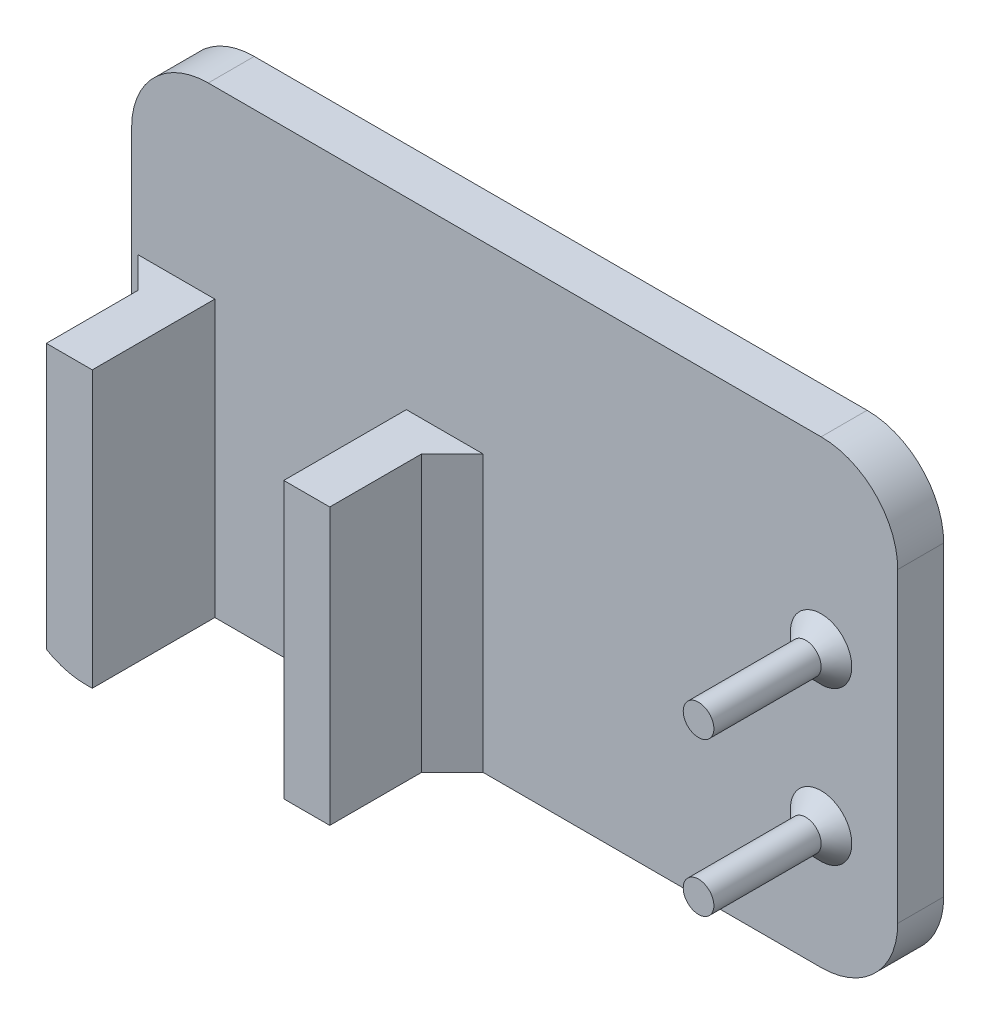
from build123d import *

# Parameters (mm, degrees)
SKETCH1_W           = 50
SKETCH1_H           = 30
BOSS_EXTRUDE1_DEPTH = 3
SKETCH2_W           = 3
SKETCH2_H           = 18
SKETCH2_R           = 1
BOSS_EXTRUDE2_DEPTH = 8
CHAMFER1_SIZE       = 2
FILLET1_R           = 5
CHAMFER3_SIZE       = 1


with BuildPart() as part:
    # Sketch1 → Boss-Extrude1 (new body)
    with BuildSketch(Plane.XY):
        with Locations((25, 15)):
            Rectangle(SKETCH1_W, SKETCH1_H)
    extrude(amount=BOSS_EXTRUDE1_DEPTH)

    # Sketch2 → Boss-Extrude2 (add)
    with BuildSketch(Plane.XY.offset(3)):
        with Locations((3.930461557, 9)):
            Rectangle(SKETCH2_W, SKETCH2_H)
        with Locations((19.430461557, 9)):
            Rectangle(SKETCH2_W, SKETCH2_H)
        with Locations((45, 18)):
            Circle(SKETCH2_R)
        with Locations((45, 8)):
            Circle(SKETCH2_R)
    extrude(amount=BOSS_EXTRUDE2_DEPTH)

    # Chamfer1
    chamfer1_edges = [part.edges().sort_by_distance(p)[0] for p in [
        (2.430461557, 9, 3),
        (20.930461557, 9, 3),
    ]]
    chamfer(chamfer1_edges, length=CHAMFER1_SIZE)

    # Fillet1
    fillet1_edges = [part.edges().sort_by_distance(p)[0] for p in [
        (0, 0, 1.5),
        (50, 0, 1.5),
        (50, 30, 1.5),
        (0, 30, 1.5),
    ]]
    fillet(fillet1_edges, radius=FILLET1_R)

    # Chamfer3
    chamfer3_edges = [part.edges().sort_by_distance(p)[0] for p in [
        (44, 18, 3),
        (44, 8, 3),
    ]]
    chamfer(chamfer3_edges, length=CHAMFER3_SIZE)


solid = part.part
